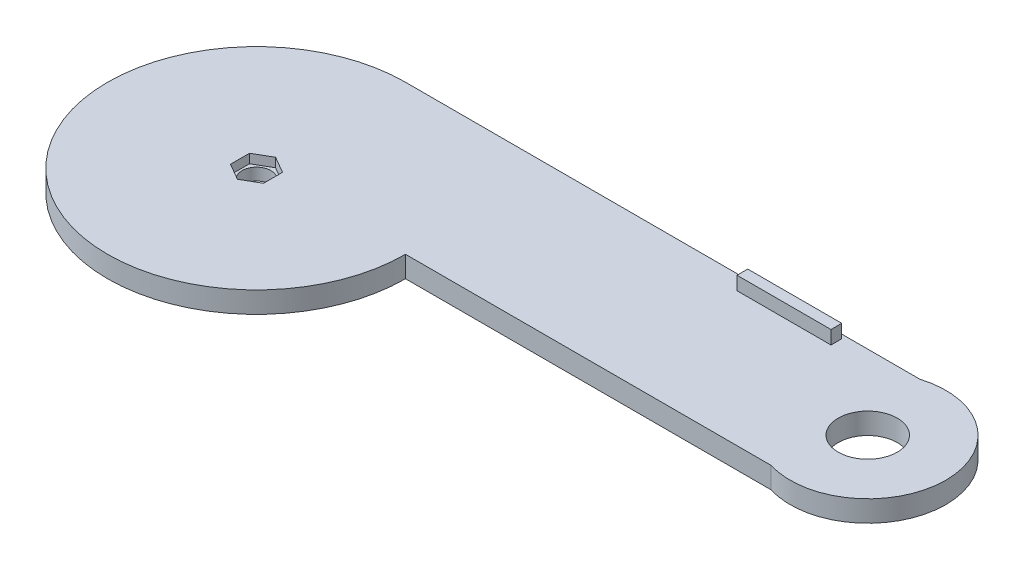
from build123d import *

# Parameters (mm, degrees)
EXTRUDE_1_DEPTH     = 7.9
SKETCH_20_W         = 35
SKETCH_20_H         = 4
EXTRUDE_10_DEPTH    = 5
SKETCH_21_R         = 11
CUT_EXTRUDE_2_DEPTH = 8.9
SKETCH_2_R          = 5.341015389
CUT_EXTRUDE_3_DEPTH = 10
CUT_EXTRUDE_4_DEPTH = 3.4


with BuildPart() as part:
    # Эскиз1 → Бобышка-Вытянуть1 (new body)
    with BuildSketch(Plane(origin=(0, 0, 0), x_dir=(1, 0, 0), z_dir=(0, 1, 0))):
        with BuildLine():
            Line((191.577559736, 55.5), (0, 55.5))
            ThreePointArc((0, 55.5), (-39.244426356, -39.244426356), (55.5, 0))
            Line((55.5, 0), (191.577559736, 0))
            ThreePointArc((191.577559736, 0), (229, 27.75), (191.577559736, 55.5))
        make_face()
    extrude(amount=EXTRUDE_1_DEPTH)

    # Эскиз20 → Бобышка-Вытянуть10 (add)
    with BuildSketch(Plane(origin=(0, 7.9, 0), x_dir=(1, 0, 0), z_dir=(0, 1, 0))):
        with Locations((146.5, 51.980071838)):
            Rectangle(SKETCH_20_W, SKETCH_20_H)
    extrude(amount=EXTRUDE_10_DEPTH)

    # Эскиз21 → Вырез-Вытянуть2 (cut, through all)
    with BuildSketch(Plane(origin=(0, 7.9, 0), x_dir=(1, 0, 0), z_dir=(0, 1, 0))):
        with Locations((199.92, 27.749938535)):
            Circle(SKETCH_21_R)
    extrude(amount=-CUT_EXTRUDE_2_DEPTH, mode=Mode.SUBTRACT)

    # Эскиз2 → Вырез-Вытянуть3 (cut)
    with BuildSketch(Plane(origin=(0, 7.9, 0), x_dir=(1, 0, 0), z_dir=(0, 1, 0))):
        Circle(SKETCH_2_R)
    extrude(amount=-CUT_EXTRUDE_3_DEPTH, mode=Mode.SUBTRACT)

    # Эскиз22 → Вырез-Вытянуть4 (cut)
    with BuildSketch(Plane(origin=(0, 7.9, 0), x_dir=(1, 0, 0), z_dir=(0, 1, 0))):
        Polygon((0, 7.1), (-6.148780367, 3.55), (-6.148780367, -3.55), (0, -7.1), (6.148780367, -3.55), (6.148780367, 3.55), align=None)
    extrude(amount=-CUT_EXTRUDE_4_DEPTH, mode=Mode.SUBTRACT)


solid = part.part
